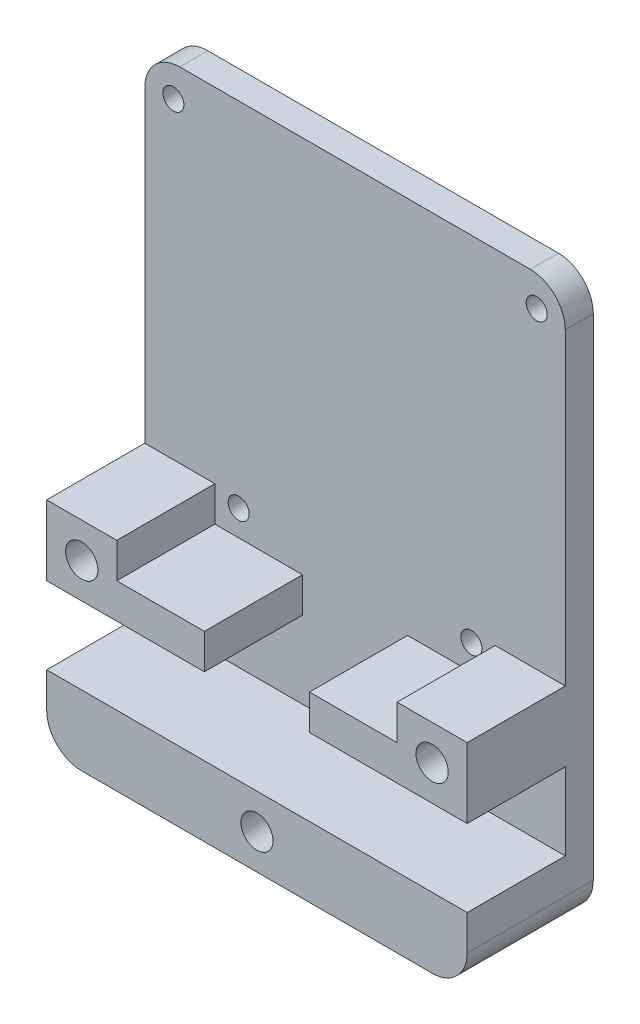
from build123d import *

# Parameters (mm, degrees)
BOSS_EXTRU_1_DEPTH      = 4
BOSS_EXTRU_2_DEPTH      = 14
ESQUISSE3_R             = 1.5
ENL_V_MAT_EXTRU_1_DEPTH = 4
ESQUISSE4_R             = 2.3
ENL_V_MAT_EXTRU_2_DEPTH = 5.7
ESQUISSE5_W             = 0.949786325
ESQUISSE5_H             = 5.291666667
ESQUISSE5_W_2           = 1.831730769
ESQUISSE5_H_2           = 0.881944444
ENL_V_MAT_EXTRU_3_DEPTH = 2


with BuildPart() as part:
    # Esquisse1 → Boss.-Extru.1 (new body)
    with BuildSketch(Plane.XY):
        with BuildLine():
            Line((5, 0), (55, 0))
            ThreePointArc((55, 0), (58.535533906, -1.464466094), (60, -5))
            Line((60, -5), (60, -75))
            ThreePointArc((60, -75), (58.535533906, -78.535533906), (55, -80))
            Line((55, -80), (5, -80))
            ThreePointArc((5, -80), (1.464466094, -78.535533906), (0, -75))
            Line((0, -75), (0, -5))
            ThreePointArc((0, -5), (1.464466094, -1.464466094), (5, 0))
        make_face()
    extrude(amount=BOSS_EXTRU_1_DEPTH)

    # Esquisse2 → Boss.-Extru.2 (add)
    with BuildSketch(Plane.XY.offset(4)):
        with BuildLine():
            ThreePointArc((0, -75), (1.464466094, -78.535533906), (5, -80))
            Line((5, -80), (55, -80))
            ThreePointArc((55, -80), (58.535533906, -78.535533906), (60, -75))
            Line((60, -75), (60, -70))
            Line((60, -70), (0, -70))
            Line((0, -70), (0, -75))
        make_face()
        Polygon((0, -49), (0, -59), (22.5, -59), (22.5, -54), (10, -54), (10, -49), align=None)
        Polygon((37.5, -54), (37.5, -59), (60, -59), (60, -49), (50, -49), (50, -54), align=None)
    extrude(amount=BOSS_EXTRU_2_DEPTH)

    # Esquisse3 → Enlèv. mat.-Extru.1 (cut)
    with BuildSketch(Plane.XY.offset(4)):
        with Locations((55.923551811, -4.402564044)):
            Circle(ESQUISSE3_R)
        with Locations((46.602959843, -50.33119663)):
            Circle(ESQUISSE3_R)
        with Locations((4.076448189, -4.402564044)):
            Circle(ESQUISSE3_R)
        with Locations((13.397040157, -50.33119663)):
            Circle(ESQUISSE3_R)
    extrude(amount=-ENL_V_MAT_EXTRU_1_DEPTH, mode=Mode.SUBTRACT)

    # Esquisse4 → Enlèv. mat.-Extru.2 (cut)
    with BuildSketch(Plane.XY.offset(18)):
        with Locations((55, -54)):
            Circle(ESQUISSE4_R)
        with Locations((5, -54)):
            Circle(ESQUISSE4_R)
        with Locations((30, -75)):
            Circle(ESQUISSE4_R)
    extrude(amount=-ENL_V_MAT_EXTRU_2_DEPTH, mode=Mode.SUBTRACT)

    # Esquisse5 → Enlèv. mat.-Extru.3 (cut)
    with BuildSketch(Plane.XZ.offset(80)):
        with BuildLine():
            Line((9.070779915, 10.868526614), (8.36056023, 10.218728604))
            add(Edge.make_bspline(
                [(8.36056023, 10.218728604), (8.330137464, 10.261643078), (8.271729996, 10.344032884), (8.177057582, 10.454354776), (8.082812663, 10.548467559), (7.988122117, 10.625978075), (7.892146642, 10.68641539), (7.795052838, 10.729205676), (7.697391157, 10.756407867), (7.631777583, 10.759795194), (7.599459135, 10.761463647)],
                knots=[0, 0, 0, 0, 0.000157741, 0.000302842, 0.000435515, 0.000556864, 0.000669227, 0.000774597, 0.000874358, 0.000971193, 0.000971193, 0.000971193, 0.000971193], degree=3))
            add(Edge.make_bspline(
                [(7.599459135, 10.761463647), (7.569313413, 10.760406438), (7.511109944, 10.758365247), (7.428136582, 10.738075955), (7.354471649, 10.703059618), (7.29018704, 10.65727281), (7.239264145, 10.602110323), (7.198606162, 10.544259056), (7.175712301, 10.480404342), (7.172699019, 10.436546348), (7.171207265, 10.414834039)],
                knots=[0, 0, 0, 0, 9.0327e-05, 0.000174397, 0.000254062, 0.00033379, 0.000409528, 0.000478324, 0.000544709, 0.000609795, 0.000609795, 0.000609795, 0.000609795], degree=3))
            add(Edge.make_bspline(
                [(7.171207265, 10.414834039), (7.172142071, 10.39280863), (7.174024641, 10.348452515), (7.192207706, 10.283443106), (7.219614776, 10.219921345), (7.245803351, 10.181252626), (7.259189704, 10.161487018)],
                knots=[0, 0, 0, 0, 6.5935e-05, 0.000132784, 0.000201129, 0.000272593, 0.000272593, 0.000272593, 0.000272593], degree=3))
            add(Edge.make_bspline(
                [(7.259189704, 10.161487018), (7.271359346, 10.146123417), (7.299372257, 10.110758437), (7.35278714, 10.054745821), (7.419865016, 9.986125465), (7.503187181, 9.90725702), (7.599294704, 9.815304068), (7.712642293, 9.713881316), (7.839967309, 9.599847819), (7.930466981, 9.520439021), (7.977889623, 9.478828097)],
                knots=[0, 0, 0, 0, 5.8772e-05, 0.000135285, 0.000231981, 0.000346684, 0.000479408, 0.000631004, 0.000802928, 0.000992196, 0.000992196, 0.000992196, 0.000992196], degree=3))
            add(Edge.make_bspline(
                [(7.977889623, 9.478828097), (8.022402595, 9.440304365), (8.106878967, 9.367194326), (8.227072069, 9.263426364), (8.332701788, 9.170068859), (8.425306907, 9.088522907), (8.503483624, 9.017932905), (8.567560593, 8.957961432), (8.618320407, 8.909776024), (8.647174388, 8.880672008), (8.659488515, 8.868251173)],
                knots=[0, 0, 0, 0, 0.000176605, 0.000335161, 0.000476363, 0.000599519, 0.000705336, 0.000792336, 0.00086281, 0.000915279, 0.000915279, 0.000915279, 0.000915279], degree=3))
            add(Edge.make_bspline(
                [(8.659488515, 8.868251173), (8.706205744, 8.817693126), (8.796012664, 8.720502805), (8.912730002, 8.569888372), (9.008792146, 8.422857975), (9.083107642, 8.276644998), (9.139233694, 8.129139878), (9.178803304, 7.976725061), (9.202501807, 7.817807908), (9.205132894, 7.709366351), (9.206463675, 7.654517533)],
                knots=[0, 0, 0, 0, 0.000206434, 0.000396838, 0.000570906, 0.000732563, 0.000887896, 0.001043446, 0.001204152, 0.001368624, 0.001368624, 0.001368624, 0.001368624], degree=3))
            add(Edge.make_bspline(
                [(9.206463675, 7.654517533), (9.205516459, 7.601074086), (9.203657986, 7.496216055), (9.18089525, 7.342771945), (9.148436925, 7.195919272), (9.09825066, 7.057256001), (9.037083938, 6.924506017), (8.960402618, 6.799737142), (8.870350922, 6.681686664), (8.767137851, 6.57246488), (8.652971939, 6.473353681), (8.530518148, 6.385122551), (8.398579064, 6.312276515), (8.258281953, 6.252293), (8.109701912, 6.206092894), (7.953015947, 6.171946711), (7.787984394, 6.15145271), (7.67513344, 6.149310305), (7.617479634, 6.148215784)],
                knots=[0, 0, 0, 0, 0.000160191, 0.0003143, 0.000464466, 0.000610642, 0.000755754, 0.000902284, 0.001048997, 0.001200474, 0.001352247, 0.001501966, 0.00165239, 0.00180341, 0.00195897, 0.002118444, 0.002283979, 0.00245688, 0.00245688, 0.00245688, 0.00245688], degree=3))
            add(Edge.make_bspline(
                [(7.617479634, 6.148215784), (7.572221887, 6.149018686), (7.482585593, 6.150608894), (7.350475247, 6.163591615), (7.222907773, 6.184544346), (7.100026866, 6.214575868), (6.981278925, 6.25262988), (6.866659072, 6.299111397), (6.756958568, 6.354740867), (6.651347365, 6.418374325), (6.550338865, 6.492261153), (6.452655855, 6.574890757), (6.359268615, 6.667534018), (6.269728626, 6.769971839), (6.184608789, 6.882494298), (6.101122827, 7.003534313), (6.022981106, 7.135338221), (5.974709489, 7.227799729), (5.950053419, 7.275027015)],
                knots=[0, 0, 0, 0, 0.00013575, 0.000268863, 0.000397821, 0.000523286, 0.000647991, 0.000771611, 0.000893919, 0.001016631, 0.001141093, 0.001268949, 0.001400123, 0.001535342, 0.001676756, 0.001823178, 0.001976248, 0.002136063, 0.002136063, 0.002136063, 0.002136063], degree=3))
            Line((5.950053419, 7.275027015), (6.785356571, 7.776420912))
            add(Edge.make_bspline(
                [(6.785356571, 7.776420912), (6.816197629, 7.722811772), (6.875322575, 7.620038469), (6.975515323, 7.481949511), (7.078157679, 7.363699176), (7.185622641, 7.267377547), (7.296603476, 7.191696679), (7.411636247, 7.137609881), (7.530801774, 7.104130214), (7.611971918, 7.100041574), (7.652460604, 7.098002108)],
                knots=[0, 0, 0, 0, 0.000185429, 0.000355484, 0.000510947, 0.000654349, 0.000787238, 0.000912434, 0.001034319, 0.001155626, 0.001155626, 0.001155626, 0.001155626], degree=3))
            add(Edge.make_bspline(
                [(7.652460604, 7.098002108), (7.693643394, 7.099667646), (7.773544005, 7.102899032), (7.887591903, 7.132746371), (7.992155334, 7.179608883), (8.082539192, 7.246475226), (8.159070544, 7.323649148), (8.215555075, 7.409508665), (8.251039038, 7.50240659), (8.254790553, 7.566939599), (8.25667735, 7.599396005)],
                knots=[0, 0, 0, 0, 0.000123333, 0.000239284, 0.000351226, 0.000465089, 0.000574534, 0.000675677, 0.000771585, 0.000868628, 0.000868628, 0.000868628, 0.000868628], degree=3))
            add(Edge.make_bspline(
                [(8.25667735, 7.599396005), (8.25493497, 7.629591409), (8.251395492, 7.690930482), (8.225324787, 7.782131819), (8.184568324, 7.87329168), (8.136350553, 7.948063465), (8.087282934, 8.010667853), (8.040363223, 8.064911723), (7.983227426, 8.124841703), (7.916020416, 8.190533181), (7.839630171, 8.262564455), (7.753992343, 8.340928472), (7.658126289, 8.424934937), (7.590367972, 8.482159312), (7.554937901, 8.512081302)],
                knots=[0, 0, 0, 0, 9.0501e-05, 0.000183843, 0.00028254, 0.000389288, 0.000449719, 0.000521119, 0.00060435, 0.000698048, 0.000803028, 0.000919327, 0.00104627, 0.001185392, 0.001185392, 0.001185392, 0.001185392], degree=3))
            add(Edge.make_bspline(
                [(7.554937901, 8.512081302), (7.487583925, 8.569069224), (7.358311259, 8.678446296), (7.17563258, 8.839992788), (7.011022734, 8.990972787), (6.865903468, 9.133252736), (6.738425737, 9.264205054), (6.629452877, 9.384893386), (6.540182004, 9.496248677), (6.446243659, 9.628141568), (6.356983449, 9.788862118), (6.279837298, 9.982227571), (6.229788132, 10.175568489), (6.224180819, 10.305366933), (6.22142094, 10.369252776)],
                knots=[0, 0, 0, 0, 0.000264676, 0.000507994, 0.000731542, 0.000934684, 0.0011176, 0.001279753, 0.00142229, 0.001545519, 0.001765234, 0.001971722, 0.002169175, 0.002360557, 0.002360557, 0.002360557, 0.002360557], degree=3))
            add(Edge.make_bspline(
                [(6.22142094, 10.369252776), (6.22256877, 10.414557187), (6.224830118, 10.503811744), (6.24500169, 10.635047565), (6.275148873, 10.761679105), (6.318931238, 10.883244355), (6.375755462, 10.999591049), (6.444766274, 11.111288754), (6.527035282, 11.21730943), (6.6197469, 11.31758279), (6.721891366, 11.409221231), (6.831045708, 11.490101338), (6.946592105, 11.558413851), (7.0678237, 11.615084042), (7.195491716, 11.658461473), (7.328655628, 11.689209558), (7.467506436, 11.707497538), (7.561949758, 11.709983577), (7.610059428, 11.711249972)],
                knots=[0, 0, 0, 0, 0.000135833, 0.000267605, 0.00039744, 0.000525861, 0.000654339, 0.000785243, 0.00091903, 0.001056299, 0.00119442, 0.001330108, 0.001463183, 0.001596448, 0.001730871, 0.001866894, 0.002005871, 0.002150175, 0.002150175, 0.002150175, 0.002150175], degree=3))
            add(Edge.make_bspline(
                [(7.610059428, 11.711249972), (7.67240718, 11.708969158), (7.79661053, 11.704425535), (7.980248767, 11.668895886), (8.159618919, 11.613021771), (8.304158748, 11.545615799), (8.419166393, 11.480319601), (8.507309009, 11.420203088), (8.596998866, 11.35133639), (8.688959255, 11.273502492), (8.781481412, 11.1852349), (8.877196183, 11.088634894), (8.974799337, 10.982867624), (9.038225912, 10.907307976), (9.070779915, 10.868526614)],
                knots=[0, 0, 0, 0, 0.000186929, 0.000372383, 0.00055912, 0.000749317, 0.000849506, 0.000955641, 0.001069069, 0.001188646, 0.001316874, 0.001452546, 0.001596585, 0.001748469, 0.001748469, 0.001748469, 0.001748469], degree=3))
        make_face()
        with BuildLine():
            Line((14.701655983, 7.037580434), (15.599500868, 5.876848262))
            Line((15.599500868, 5.876848262), (14.41650808, 5.876848262))
            Line((14.41650808, 5.876848262), (13.951155182, 6.477884921))
            add(Edge.make_bspline(
                [(13.951155182, 6.477884921), (13.902410877, 6.451343189), (13.805152194, 6.398384924), (13.652637751, 6.332346391), (13.497299991, 6.274412569), (13.336888026, 6.229015651), (13.172941949, 6.193282765), (13.004612285, 6.166000121), (12.832019483, 6.151614589), (12.715537544, 6.149354375), (12.656859308, 6.148215784)],
                knots=[0, 0, 0, 0, 0.000166428, 0.000332071, 0.000498076, 0.000663485, 0.000831696, 0.001001264, 0.001174685, 0.00135073, 0.00135073, 0.00135073, 0.00135073], degree=3))
            add(Edge.make_bspline(
                [(12.656859308, 6.148215784), (12.559543707, 6.150453356), (12.367981748, 6.154857929), (12.08769118, 6.195726237), (11.819203918, 6.258530067), (11.563893835, 6.349379425), (11.32040608, 6.465140696), (11.090973572, 6.608556123), (10.872937793, 6.775695194), (10.671630507, 6.968185769), (10.487437633, 7.176785904), (10.326497058, 7.398407586), (10.189687011, 7.629593292), (10.078114546, 7.870705609), (9.991355616, 8.12216023), (9.930599023, 8.383270347), (9.892080315, 8.654396813), (9.887305821, 8.838439992), (9.884882479, 8.931852936)],
                knots=[0, 0, 0, 0, 0.000291785, 0.000574368, 0.000847932, 0.001117823, 0.001385709, 0.001655157, 0.001928029, 0.002208463, 0.002489372, 0.002761833, 0.003028895, 0.003294017, 0.003557506, 0.003825423, 0.004097215, 0.004377352, 0.004377352, 0.004377352, 0.004377352], degree=3))
            add(Edge.make_bspline(
                [(9.884882479, 8.931852936), (9.885690327, 8.994445179), (9.887295795, 9.118837104), (9.906605037, 9.303183897), (9.934464255, 9.483915611), (9.975368671, 9.660060785), (10.025806622, 9.832911694), (10.089981998, 10.001094), (10.164355254, 10.166204728), (10.249677841, 10.326872207), (10.346592799, 10.480720886), (10.449579694, 10.628973225), (10.564136301, 10.766869144), (10.68620796, 10.897514103), (10.816195633, 11.02082253), (10.95614643, 11.134252773), (11.103400898, 11.240619766), (11.259020035, 11.337693549), (11.420302243, 11.425438826), (11.585763112, 11.501695423), (11.754143272, 11.566932183), (11.925505547, 11.620075134), (12.100371184, 11.659900418), (12.277201506, 11.690223044), (12.457599957, 11.707090342), (12.578738206, 11.709854431), (12.639898838, 11.711249972)],
                knots=[0, 0, 0, 0, 0.0001877, 0.000373023, 0.000555487, 0.000736004, 0.000915108, 0.001095253, 0.001275536, 0.001458111, 0.001640476, 0.001820759, 0.001999238, 0.002177732, 0.002356953, 0.002536251, 0.002717764, 0.00290159, 0.003086102, 0.00326823, 0.003447763, 0.003627481, 0.003805931, 0.003985427, 0.004165373, 0.004348869, 0.004348869, 0.004348869, 0.004348869], degree=3))
            add(Edge.make_bspline(
                [(12.639898838, 11.711249972), (12.73226122, 11.708901366), (12.914261451, 11.704273434), (13.181982609, 11.664700456), (13.440157504, 11.601661656), (13.687721556, 11.510582939), (13.926187877, 11.395744842), (14.153179836, 11.253651029), (14.371099424, 11.08723169), (14.575238822, 10.896406908), (14.763893675, 10.689316068), (14.928356192, 10.467130677), (15.067583608, 10.234092979), (15.183693135, 9.990110066), (15.271168845, 9.733756041), (15.333616005, 9.466732931), (15.37314324, 9.188852876), (15.377739125, 8.999475197), (15.380074786, 8.903232143)],
                knots=[0, 0, 0, 0, 0.00027696, 0.00054575, 0.000810044, 0.001072953, 0.001335603, 0.00160269, 0.001874918, 0.002156945, 0.002439886, 0.002714226, 0.002984736, 0.003253124, 0.003523317, 0.003795604, 0.004074891, 0.0043635, 0.0043635, 0.0043635, 0.0043635], degree=3))
            add(Edge.make_bspline(
                [(15.380074786, 8.903232143), (15.378133015, 8.814440505), (15.374313934, 8.639804853), (15.341228163, 8.382355671), (15.289004758, 8.134209144), (15.213999211, 7.895188923), (15.118946591, 7.665555532), (15.000510741, 7.445992604), (14.863939262, 7.233893477), (14.756020092, 7.103344349), (14.701655983, 7.037580434)],
                knots=[0, 0, 0, 0, 0.000266278, 0.000523717, 0.000777363, 0.001026134, 0.001274181, 0.001521729, 0.001773697, 0.002029472, 0.002029472, 0.002029472, 0.002029472], degree=3))
        make_face()
        with BuildLine():
            add(Edge.make_bspline(
                [(14.078358707, 7.845322821), (14.106630862, 7.885856341), (14.162523804, 7.96598952), (14.23324642, 8.093091639), (14.293997947, 8.222670291), (14.344237081, 8.355405425), (14.382453933, 8.492057723), (14.409617608, 8.631735076), (14.427605883, 8.774501451), (14.429389593, 8.870670113), (14.430288462, 8.919132584)],
                knots=[0, 0, 0, 0, 0.000148177, 0.00029294, 0.000435682, 0.000577243, 0.000718191, 0.000860803, 0.001003856, 0.001149177, 0.001149177, 0.001149177, 0.001149177], degree=3))
            add(Edge.make_bspline(
                [(14.430288462, 8.919132584), (14.428615522, 8.98210426), (14.425322597, 9.106054401), (14.400590092, 9.288262934), (14.359156726, 9.462884521), (14.301384114, 9.630346567), (14.228628656, 9.791078946), (14.13723243, 9.943743282), (14.029853869, 10.089132488), (13.907529525, 10.225846406), (13.774350427, 10.350969905), (13.632711222, 10.461166941), (13.483583506, 10.554133618), (13.32688004, 10.62919814), (13.164300681, 10.689657285), (12.994100706, 10.730237774), (12.817763595, 10.756845095), (12.697592619, 10.759910721), (12.63671875, 10.761463647)],
                knots=[0, 0, 0, 0, 0.000188876, 0.000371773, 0.000550466, 0.000726459, 0.000902443, 0.001078785, 0.001259208, 0.001443896, 0.001628384, 0.001806702, 0.001981427, 0.002154475, 0.002327182, 0.002500723, 0.002678517, 0.002861039, 0.002861039, 0.002861039, 0.002861039], degree=3))
            add(Edge.make_bspline(
                [(12.63671875, 10.761463647), (12.574092031, 10.759825131), (12.450829249, 10.75660018), (12.269868851, 10.731390701), (12.096289609, 10.691848693), (11.931003929, 10.633791015), (11.773511356, 10.560637075), (11.623819115, 10.470875768), (11.482677403, 10.364004478), (11.349750652, 10.243153559), (11.229646684, 10.109052672), (11.123587779, 9.965251559), (11.034819227, 9.812096974), (10.960478815, 9.65098361), (10.904516016, 9.480107285), (10.864655642, 9.300804477), (10.839465309, 9.112766792), (10.836290042, 8.984581726), (10.834668803, 8.919132584)],
                knots=[0, 0, 0, 0, 0.000187817, 0.000369664, 0.000547082, 0.000721072, 0.000894168, 0.001067236, 0.001243625, 0.001424455, 0.001605361, 0.00178282, 0.001959537, 0.002135521, 0.002314188, 0.002497806, 0.002685957, 0.002882246, 0.002882246, 0.002882246, 0.002882246], degree=3))
            add(Edge.make_bspline(
                [(10.834668803, 8.919132584), (10.836817846, 8.846599879), (10.841029613, 8.704447796), (10.870677316, 8.49708582), (10.921366223, 8.301231684), (10.994681259, 8.117942767), (11.085278925, 7.944638418), (11.199416501, 7.785009706), (11.332137521, 7.635900404), (11.434588535, 7.549105548), (11.486586872, 7.50505339)],
                knots=[0, 0, 0, 0, 0.000217564, 0.00042639, 0.000626938, 0.000822994, 0.001017417, 0.001212116, 0.001410276, 0.001614507, 0.001614507, 0.001614507, 0.001614507], degree=3))
            add(Edge.make_bspline(
                [(11.486586872, 7.50505339), (11.529131407, 7.472443601), (11.613500811, 7.407775636), (11.748653176, 7.325919033), (11.887176403, 7.254809838), (12.030380302, 7.197958809), (12.17777017, 7.152745407), (12.329314666, 7.121425908), (12.485309808, 7.101489705), (12.590722994, 7.099175025), (12.644138956, 7.098002108)],
                knots=[0, 0, 0, 0, 0.000160705, 0.000318693, 0.000473239, 0.000627367, 0.000780276, 0.00093516, 0.001091096, 0.001251286, 0.001251286, 0.001251286, 0.001251286], degree=3))
            add(Edge.make_bspline(
                [(12.644138956, 7.098002108), (12.705401527, 7.10008179), (12.826935315, 7.104207499), (13.005938566, 7.135978438), (13.179768275, 7.187287451), (13.288855403, 7.238600932), (13.343758347, 7.264426721)],
                knots=[0, 0, 0, 0, 0.000183691, 0.00036441, 0.000543818, 0.000725606, 0.000725606, 0.000725606, 0.000725606], degree=3))
            Line((13.343758347, 7.264426721), (12.424712874, 8.454839715))
            Line((12.424712874, 8.454839715), (13.607705662, 8.454839715))
            Line((13.607705662, 8.454839715), (14.078358707, 7.845322821))
        make_face(mode=Mode.SUBTRACT)
        with BuildLine():
            Line((16.329861111, 11.575566211), (17.279647436, 11.575566211))
            Line((17.279647436, 11.575566211), (17.279647436, 8.132590784))
            add(Edge.make_bspline(
                [(17.279647436, 8.132590784), (17.279699081, 8.096895508), (17.279798832, 8.027950451), (17.284792429, 7.929036868), (17.289361914, 7.838114574), (17.297606563, 7.755283111), (17.309786735, 7.680507046), (17.321581116, 7.613306045), (17.337543645, 7.554883264), (17.361532774, 7.488382844), (17.398492146, 7.41366599), (17.458881709, 7.335794371), (17.528566099, 7.264725216), (17.612086854, 7.205569944), (17.705956796, 7.157718661), (17.809660152, 7.122266156), (17.923050736, 7.10255927), (18.001454106, 7.099550653), (18.04180856, 7.098002108)],
                knots=[0, 0, 0, 0, 0.000107068, 0.000206801, 0.000297059, 0.000380175, 0.000456335, 0.000524318, 0.000584749, 0.000637729, 0.000736335, 0.000833222, 0.000932163, 0.001033948, 0.001138719, 0.001247329, 0.001361483, 0.001482554, 0.001482554, 0.001482554, 0.001482554], degree=3))
            add(Edge.make_bspline(
                [(18.04180856, 7.098002108), (18.084680189, 7.099253133), (18.168272605, 7.101692421), (18.288506989, 7.125636665), (18.399904828, 7.163764102), (18.500107449, 7.218181672), (18.589015134, 7.283410667), (18.664273627, 7.357792161), (18.723667354, 7.44147451), (18.762377975, 7.518677849), (18.784112082, 7.589736799), (18.800402878, 7.653225275), (18.812345834, 7.728135392), (18.823180876, 7.813297268), (18.829691902, 7.909593014), (18.836752047, 8.016248209), (18.839339656, 8.133992615), (18.839780695, 8.215980256), (18.840010684, 8.25873428)],
                knots=[0, 0, 0, 0, 0.000128478, 0.00025051, 0.00036617, 0.000480467, 0.000591137, 0.000696075, 0.000796381, 0.000897834, 0.000953483, 0.001019042, 0.001094326, 0.001180841, 0.001276531, 0.001383783, 0.001501489, 0.001629757, 0.001629757, 0.001629757, 0.001629757], degree=3))
            Line((18.840010684, 8.25873428), (18.840010684, 11.575566211))
            Line((18.840010684, 11.575566211), (19.789797009, 11.575566211))
            Line((19.789797009, 11.575566211), (19.789797009, 8.418798716))
            add(Edge.make_bspline(
                [(19.789797009, 8.418798716), (19.789665113, 8.354842758), (19.789411492, 8.231861687), (19.785516632, 8.055129233), (19.777225179, 7.893712486), (19.770261315, 7.74756428), (19.756783854, 7.616881501), (19.742743501, 7.501106095), (19.724847863, 7.400648345), (19.698220229, 7.286289404), (19.652268817, 7.154609273), (19.578189117, 7.00298531), (19.484149732, 6.854536265), (19.372999878, 6.710895182), (19.247501526, 6.577457244), (19.110437243, 6.460316007), (18.96398464, 6.361227153), (18.806613391, 6.282613522), (18.638457428, 6.221300816), (18.457852973, 6.180101766), (18.264923184, 6.152267171), (18.131662932, 6.149593316), (18.063009148, 6.148215784)],
                knots=[0, 0, 0, 0, 0.000191868, 0.000368944, 0.000530239, 0.000676769, 0.000807771, 0.000924264, 0.001026566, 0.001113728, 0.001276313, 0.001443667, 0.001618954, 0.001802572, 0.001987786, 0.002167494, 0.002342425, 0.002516879, 0.002693933, 0.002878027, 0.003071714, 0.003277535, 0.003277535, 0.003277535, 0.003277535], degree=3))
            add(Edge.make_bspline(
                [(18.063009148, 6.148215784), (18.017394208, 6.148984107), (17.927396868, 6.150499993), (17.79503999, 6.163866151), (17.667091068, 6.183562842), (17.543790516, 6.212298286), (17.424710382, 6.249419112), (17.309882303, 6.295112263), (17.199733006, 6.34912287), (17.094878872, 6.410954151), (16.995448934, 6.477814037), (16.904575102, 6.551931036), (16.819130196, 6.627823915), (16.741582683, 6.708686568), (16.671350112, 6.793670076), (16.608577128, 6.88296704), (16.553356989, 6.976569527), (16.504300664, 7.076164717), (16.462313238, 7.186814674), (16.42691626, 7.312455262), (16.395992627, 7.455055773), (16.373012008, 7.614937476), (16.352177644, 7.791573421), (16.33899064, 7.985423771), (16.332091925, 8.196494088), (16.330623505, 8.342824762), (16.329861111, 8.418798716)],
                knots=[0, 0, 0, 0, 0.00013681, 0.000269922, 0.00039871, 0.000524961, 0.000649346, 0.00077257, 0.000895355, 0.001016981, 0.001137527, 0.001254404, 0.001368494, 0.0014802, 0.001590137, 0.001698949, 0.001807301, 0.001915864, 0.002031621, 0.002161794, 0.002307126, 0.002469036, 0.00264615, 0.002840624, 0.003051701, 0.003279629, 0.003279629, 0.003279629, 0.003279629], degree=3))
            Line((16.329861111, 8.418798716), (16.329861111, 11.575566211))
        make_face()
        with Locations((21.350160257, 8.929732878)):
            Rectangle(ESQUISSE5_W, ESQUISSE5_H)
        with BuildLine():
            Line((23.046207265, 11.575566211), (24.152877938, 11.575566211))
            add(Edge.make_bspline(
                [(24.152877938, 11.575566211), (24.226028533, 11.575306568), (24.366717732, 11.574807202), (24.569583872, 11.566928531), (24.755944321, 11.555964713), (24.926075001, 11.539233636), (25.079903128, 11.51705025), (25.217582875, 11.49089971), (25.339110215, 11.461095562), (25.445510066, 11.423957242), (25.541530669, 11.38206578), (25.631035221, 11.333931723), (25.715998325, 11.280091057), (25.795852094, 11.21912709), (25.871290477, 11.152136548), (25.942455791, 11.079051999), (26.008342407, 10.999253715), (26.06854235, 10.913245921), (26.123409752, 10.822767694), (26.171901029, 10.727694806), (26.211334215, 10.627961142), (26.246177662, 10.525008067), (26.271274269, 10.417363849), (26.288728591, 10.30607642), (26.301507963, 10.190754038), (26.302242716, 10.112409132), (26.302617521, 10.07244455)],
                knots=[0, 0, 0, 0, 0.000219436, 0.000422038, 0.000608967, 0.000779418, 0.000934726, 0.001075054, 0.001199746, 0.001309704, 0.001412707, 0.001513721, 0.00161429, 0.001714147, 0.001814766, 0.001916717, 0.002019867, 0.002124858, 0.002231389, 0.002337106, 0.002444582, 0.002552856, 0.0026629, 0.002775653, 0.002890728, 0.003010554, 0.003010554, 0.003010554, 0.003010554], degree=3))
            add(Edge.make_bspline(
                [(26.302617521, 10.07244455), (26.301643912, 10.030730706), (26.299734841, 9.948937462), (26.289451548, 9.828789858), (26.270656917, 9.713841034), (26.242189715, 9.604427546), (26.209470364, 9.499187617), (26.16596202, 9.400062988), (26.116858553, 9.305612035), (26.058539801, 9.217170804), (25.994537819, 9.132774837), (25.92010486, 9.055657657), (25.840063037, 8.981674508), (25.749912908, 8.915459443), (25.653628373, 8.852535239), (25.54929636, 8.795509153), (25.437597776, 8.74294768), (25.35906814, 8.713635772), (25.318910256, 8.698646473)],
                knots=[0, 0, 0, 0, 0.000125155, 0.000245407, 0.000361469, 0.000474077, 0.000584366, 0.00069168, 0.00079837, 0.000903334, 0.001009136, 0.001115615, 0.001224427, 0.00133573, 0.001450693, 0.001569302, 0.001692129, 0.001820672, 0.001820672, 0.001820672, 0.001820672], degree=3))
            Line((25.318910256, 8.698646473), (26.540064103, 6.283899544))
            Line((26.540064103, 6.283899544), (25.48427484, 6.283899544))
            Line((25.48427484, 6.283899544), (24.318242521, 8.590523476))
            Line((24.318242521, 8.590523476), (23.99599359, 8.590523476))
            Line((23.99599359, 8.590523476), (23.99599359, 6.283899544))
            Line((23.99599359, 6.283899544), (23.046207265, 6.283899544))
            Line((23.046207265, 6.283899544), (23.046207265, 11.575566211))
        make_face()
        with BuildLine():
            Line((23.99599359, 9.540309801), (24.365943843, 9.540309801))
            add(Edge.make_bspline(
                [(24.365943843, 9.540309801), (24.411173337, 9.540819206), (24.497778099, 9.541794607), (24.622327121, 9.546318921), (24.735447337, 9.557220283), (24.837624523, 9.570993746), (24.929372824, 9.586897199), (25.009873879, 9.609687812), (25.080368086, 9.63410853), (25.140020085, 9.664457149), (25.190985383, 9.69897011), (25.234990656, 9.738177693), (25.271389326, 9.783555477), (25.301347288, 9.833870291), (25.324651325, 9.889567156), (25.341661487, 9.950034647), (25.351167653, 10.015961567), (25.352261369, 10.061460119), (25.352831197, 10.085164902)],
                knots=[0, 0, 0, 0, 0.0001357, 0.000259837, 0.000373754, 0.000476446, 0.000569173, 0.000652754, 0.000727198, 0.00079262, 0.000852893, 0.000911435, 0.000968715, 0.001026708, 0.00108656, 0.001149317, 0.001214678, 0.001285772, 0.001285772, 0.001285772, 0.001285772], degree=3))
            add(Edge.make_bspline(
                [(25.352831197, 10.085164902), (25.351753886, 10.113209392), (25.349637709, 10.168297594), (25.328638656, 10.24760529), (25.295212699, 10.321009988), (25.249394868, 10.388180028), (25.191693266, 10.447065923), (25.125476125, 10.498974307), (25.04931432, 10.540019574), (24.97879422, 10.567092595), (24.914637413, 10.583290663), (24.856737918, 10.595361319), (24.789689954, 10.60391614), (24.713442904, 10.612990051), (24.628191124, 10.618874022), (24.533469941, 10.623168149), (24.429551394, 10.624925087), (24.357110296, 10.625486749), (24.319302551, 10.625779886)],
                knots=[0, 0, 0, 0, 8.3983e-05, 0.00016497, 0.000244189, 0.000325044, 0.000407508, 0.000490624, 0.000576493, 0.00066607, 0.000716464, 0.000774881, 0.00084339, 0.000919128, 0.001005226, 0.001099664, 0.001203568, 0.001316997, 0.001316997, 0.001316997, 0.001316997], degree=3))
            Line((24.319302551, 10.625779886), (23.99599359, 10.625779886))
            Line((23.99599359, 10.625779886), (23.99599359, 9.540309801))
        make_face(mode=Mode.SUBTRACT)
        Polygon((27.320245726, 11.575566211), (28.270032051, 11.575566211), (28.270032051, 7.233685869), (29.762553419, 7.233685869), (29.762553419, 6.283899544), (27.320245726, 6.283899544), align=None)
        Polygon((30.576655983, 11.575566211), (33.426014957, 11.575566211), (33.426014957, 10.625779886), (31.526442308, 10.625779886), (31.526442308, 9.608151681), (33.426014957, 9.608151681), (33.426014957, 8.658365356), (31.526442308, 8.658365356), (31.526442308, 7.233685869), (33.426014957, 7.233685869), (33.426014957, 6.283899544), (30.576655983, 6.283899544), align=None)
        with BuildLine():
            Line((34.375801282, 6.283899544), (34.375801282, 11.575566211))
            Line((34.375801282, 11.575566211), (35.223824786, 11.575566211))
            add(Edge.make_bspline(
                [(35.223824786, 11.575566211), (35.283191734, 11.575572986), (35.398065652, 11.575586096), (35.563798737, 11.569766094), (35.717502177, 11.56223727), (35.858686828, 11.553814266), (35.987592995, 11.539299748), (36.104024656, 11.524003031), (36.208214443, 11.505556134), (36.272629327, 11.489008695), (36.302934696, 11.481223596)],
                knots=[0, 0, 0, 0, 0.000178088, 0.000344597, 0.000497422, 0.000639786, 0.000768787, 0.00088647, 0.00099209, 0.001085931, 0.001085931, 0.001085931, 0.001085931], degree=3))
            add(Edge.make_bspline(
                [(36.302934696, 11.481223596), (36.342728722, 11.470242575), (36.420817377, 11.448694288), (36.53266525, 11.40517659), (36.63876856, 11.356803583), (36.738997757, 11.301619029), (36.832737395, 11.238956696), (36.919631229, 11.168319278), (37.001553346, 11.092542156), (37.075594878, 11.009513444), (37.142516224, 10.92177823), (37.200658875, 10.829359502), (37.251177387, 10.733670403), (37.291605428, 10.633506751), (37.322067198, 10.529329824), (37.34434681, 10.421584475), (37.358787015, 10.309929772), (37.360151425, 10.233967428), (37.360844017, 10.195407958)],
                knots=[0, 0, 0, 0, 0.000123769, 0.000242875, 0.000359556, 0.000473429, 0.000585737, 0.000697317, 0.000809064, 0.00092016, 0.001030616, 0.001139722, 0.001247351, 0.001354827, 0.001463163, 0.001572516, 0.001684669, 0.00180029, 0.00180029, 0.00180029, 0.00180029], degree=3))
            add(Edge.make_bspline(
                [(37.360844017, 10.195407958), (37.359033094, 10.14586916), (37.355468515, 10.048358123), (37.332697742, 9.905132052), (37.289998993, 9.769762829), (37.234128719, 9.639755649), (37.158162614, 9.515595441), (37.061700352, 9.397341239), (36.946304307, 9.28135182), (36.85778917, 9.211823986), (36.811748798, 9.175659694)],
                knots=[0, 0, 0, 0, 0.000148646, 0.000292592, 0.00043342, 0.000573448, 0.000716159, 0.000868464, 0.001030368, 0.001205863, 0.001205863, 0.001205863, 0.001205863], degree=3))
            add(Edge.make_bspline(
                [(36.811748798, 9.175659694), (36.849057707, 9.156613819), (36.922210155, 9.119270129), (37.02606514, 9.05788825), (37.12222352, 8.992600836), (37.211116439, 8.924721498), (37.290879267, 8.851372731), (37.364805545, 8.776780991), (37.429248134, 8.696672484), (37.486874639, 8.613902427), (37.536962661, 8.527272302), (37.580583804, 8.436928407), (37.617429019, 8.342562108), (37.648630501, 8.244653652), (37.671900574, 8.142866281), (37.687073156, 8.037163591), (37.698690234, 7.927906082), (37.699593933, 7.853482595), (37.700053419, 7.815641999)],
                knots=[0, 0, 0, 0, 0.000125648, 0.000246361, 0.000361612, 0.0004742, 0.000581515, 0.000686463, 0.000788941, 0.000889504, 0.000988774, 0.001088811, 0.001190187, 0.00129244, 0.00139684, 0.001502981, 0.001612677, 0.001726145, 0.001726145, 0.001726145, 0.001726145], degree=3))
            add(Edge.make_bspline(
                [(37.700053419, 7.815641999), (37.697071664, 7.743368624), (37.691187183, 7.600737408), (37.648162726, 7.391322026), (37.57357199, 7.19277725), (37.473412012, 7.005892181), (37.349995648, 6.836076837), (37.208102221, 6.687320069), (37.049160273, 6.561400768), (36.902517115, 6.476415008), (36.775682332, 6.419381616), (36.670627451, 6.384119976), (36.557800735, 6.351453646), (36.43513547, 6.328514675), (36.304855411, 6.307518406), (36.165690318, 6.294554875), (36.017900288, 6.285769809), (35.916391707, 6.28453557), (35.864082532, 6.283899544)],
                knots=[0, 0, 0, 0, 0.000216755, 0.000427764, 0.000638059, 0.000851001, 0.001061971, 0.001265899, 0.001465886, 0.00166824, 0.001772641, 0.001882598, 0.002000395, 0.002124713, 0.002256643, 0.002396189, 0.002543777, 0.002700693, 0.002700693, 0.002700693, 0.002700693], degree=3))
            Line((35.864082532, 6.283899544), (34.375801282, 6.283899544))
        make_face()
        with BuildLine():
            Line((35.325587607, 10.625779886), (35.325587607, 9.47246792))
            Line((35.325587607, 9.47246792), (35.577874599, 9.47246792))
            add(Edge.make_bspline(
                [(35.577874599, 9.47246792), (35.612162668, 9.472766925), (35.67835371, 9.473344136), (35.77395965, 9.480778413), (35.862857733, 9.49346175), (35.94471079, 9.511158196), (36.020281311, 9.533630102), (36.08908653, 9.560668645), (36.150823923, 9.593658606), (36.222548494, 9.64279861), (36.298366538, 9.715110324), (36.36510831, 9.819579578), (36.404418768, 9.939718823), (36.408796892, 10.024450321), (36.411057692, 10.068204432)],
                knots=[0, 0, 0, 0, 0.000102845, 0.000198535, 0.000287433, 0.000372056, 0.000449525, 0.000523735, 0.000593447, 0.000659015, 0.000784211, 0.00090478, 0.001027469, 0.001158471, 0.001158471, 0.001158471, 0.001158471], degree=3))
            add(Edge.make_bspline(
                [(36.411057692, 10.068204432), (36.409248639, 10.109187427), (36.405750906, 10.1884264), (36.366170329, 10.299684976), (36.304693868, 10.398282844), (36.232112266, 10.465765022), (36.163762583, 10.511853359), (36.105237391, 10.542200567), (36.041001597, 10.569367077), (35.969811666, 10.590139253), (35.892074132, 10.605725963), (35.808166609, 10.617172534), (35.717944328, 10.624963558), (35.655627606, 10.62550194), (35.623455863, 10.625779886)],
                knots=[0, 0, 0, 0, 0.00012246, 0.000236771, 0.000349698, 0.000468165, 0.000530788, 0.000596697, 0.000665599, 0.000739718, 0.000818717, 0.000903267, 0.000993675, 0.001090161, 0.001090161, 0.001090161, 0.001090161], degree=3))
            Line((35.623455863, 10.625779886), (35.325587607, 10.625779886))
        make_face(mode=Mode.SUBTRACT)
        with BuildLine():
            Line((35.325587607, 8.590523476), (35.325587607, 7.233685869))
            Line((35.325587607, 7.233685869), (35.599075187, 7.233685869))
            add(Edge.make_bspline(
                [(35.599075187, 7.233685869), (35.65314403, 7.233994762), (35.757098127, 7.234588648), (35.906012187, 7.241764202), (36.041412296, 7.254696874), (36.162939695, 7.270842272), (36.270780526, 7.292716762), (36.364570262, 7.320527373), (36.445595106, 7.351123888), (36.51336923, 7.388914218), (36.568736807, 7.43289279), (36.61870024, 7.477839947), (36.65943731, 7.529690739), (36.69166924, 7.586219356), (36.719565919, 7.646021585), (36.736391225, 7.711432683), (36.749201423, 7.78051402), (36.749906402, 7.828296087), (36.750267094, 7.852743027)],
                knots=[0, 0, 0, 0, 0.000162198, 0.000311847, 0.00044707, 0.000570148, 0.0006795, 0.000776769, 0.000863381, 0.000938852, 0.001008395, 0.001075143, 0.001140039, 0.001205125, 0.001270133, 0.001337259, 0.001407141, 0.001480352, 0.001480352, 0.001480352, 0.001480352], degree=3))
            add(Edge.make_bspline(
                [(36.750267094, 7.852743027), (36.749471665, 7.880698487), (36.747922385, 7.935148203), (36.73526939, 8.014732275), (36.712274765, 8.089029285), (36.683311913, 8.159939111), (36.643008565, 8.224922932), (36.595109414, 8.286229592), (36.537235011, 8.341783059), (36.472151869, 8.394943414), (36.396238827, 8.441488185), (36.30946027, 8.481874018), (36.211344768, 8.515602778), (36.1015884, 8.54245764), (35.980672327, 8.565248989), (35.847713996, 8.578857941), (35.70382073, 8.588979516), (35.604042797, 8.589997129), (35.552433894, 8.590523476)],
                knots=[0, 0, 0, 0, 8.385e-05, 0.000163316, 0.000240786, 0.000316783, 0.00039241, 0.000469392, 0.000549598, 0.000632538, 0.00072108, 0.000815922, 0.000919176, 0.001031783, 0.00115466, 0.001287992, 0.001432471, 0.001587268, 0.001587268, 0.001587268, 0.001587268], degree=3))
            Line((35.552433894, 8.590523476), (35.325587607, 8.590523476))
        make_face(mode=Mode.SUBTRACT)
        with BuildLine():
            add(Edge.make_bspline(
                [(41.13666867, 11.711249972), (41.22867078, 11.708867872), (41.410303784, 11.704165068), (41.677420388, 11.664963529), (41.934836625, 11.60109024), (42.182436094, 11.51230175), (42.419598832, 11.396193213), (42.647161393, 11.256056383), (42.864308659, 11.089246262), (43.068815477, 10.899654254), (43.257816661, 10.693481224), (43.421586297, 10.471499303), (43.561243035, 10.239460265), (43.676990912, 9.996742354), (43.765154466, 9.741664634), (43.827022478, 9.475527664), (43.86676961, 9.198407156), (43.871341142, 9.009725863), (43.87366453, 8.913832437)],
                knots=[0, 0, 0, 0, 0.000275901, 0.000544691, 0.000807956, 0.001070504, 0.0013322, 0.001598729, 0.001870957, 0.002152264, 0.002434419, 0.00270876, 0.00297836, 0.00324579, 0.00351398, 0.003786267, 0.004064504, 0.004352054, 0.004352054, 0.004352054, 0.004352054], degree=3))
            add(Edge.make_bspline(
                [(43.87366453, 8.913832437), (43.871190222, 8.819019508), (43.86631452, 8.63218759), (43.82864513, 8.357620858), (43.765735253, 8.094334769), (43.679067022, 7.841733369), (43.565418373, 7.601040174), (43.428485094, 7.370718391), (43.264653776, 7.15290546), (43.07989999, 6.947718269), (42.876502105, 6.761466864), (42.661071456, 6.597333136), (42.434602768, 6.458252408), (42.19742752, 6.344288387), (41.9490371, 6.255845108), (41.690045063, 6.193441947), (41.420467436, 6.155518287), (41.237141576, 6.150674432), (41.144088876, 6.148215784)],
                knots=[0, 0, 0, 0, 0.000284373, 0.000560365, 0.000829558, 0.001095398, 0.001360006, 0.001626698, 0.001897854, 0.002176303, 0.002453897, 0.002723997, 0.00298761, 0.003249799, 0.003511989, 0.00377706, 0.004047801, 0.004326879, 0.004326879, 0.004326879, 0.004326879], degree=3))
            add(Edge.make_bspline(
                [(41.144088876, 6.148215784), (41.046766908, 6.150421312), (40.855542544, 6.154754874), (40.575684832, 6.195965073), (40.307556962, 6.258042028), (40.053411363, 6.350688554), (39.810659778, 6.466504501), (39.581085776, 6.609138783), (39.364766508, 6.778355686), (39.162942817, 6.969821503), (38.980090063, 7.179327102), (38.818686642, 7.400651188), (38.682539276, 7.63210304), (38.571642983, 7.873790983), (38.484216801, 8.124212985), (38.422547562, 8.384894188), (38.386118072, 8.655209383), (38.381043655, 8.838812868), (38.378472222, 8.931852936)],
                knots=[0, 0, 0, 0, 0.000291785, 0.000573319, 0.000846882, 0.001116132, 0.001383061, 0.001652509, 0.001925192, 0.002205626, 0.002485836, 0.002758297, 0.003026273, 0.003289988, 0.003554826, 0.00382068, 0.004092329, 0.004371406, 0.004371406, 0.004371406, 0.004371406], degree=3))
            add(Edge.make_bspline(
                [(38.378472222, 8.931852936), (38.379279286, 8.994445424), (38.380883194, 9.118837834), (38.40020396, 9.303181037), (38.428020308, 9.483926108), (38.469159366, 9.660352414), (38.519132807, 9.83370456), (38.583880459, 10.002368943), (38.65758081, 10.16814736), (38.74369273, 10.329081762), (38.839440859, 10.483691418), (38.943910592, 10.631247006), (39.057364618, 10.769964364), (39.179437463, 10.900755086), (39.310549807, 11.022759474), (39.448977002, 11.137704671), (39.59740373, 11.242537323), (39.752581395, 11.339817653), (39.913635142, 11.427786569), (40.079909335, 11.502663078), (40.247978398, 11.568051459), (40.420087507, 11.61965886), (40.594392207, 11.661692548), (40.77275459, 11.689490148), (40.953563253, 11.708810378), (41.075488682, 11.710434844), (41.13666867, 11.711249972)],
                knots=[0, 0, 0, 0, 0.0001877, 0.000373023, 0.000555487, 0.000736004, 0.000916124, 0.00109627, 0.00127752, 0.001460094, 0.00164336, 0.001822777, 0.002002076, 0.00218057, 0.002359065, 0.002539036, 0.002719932, 0.002903758, 0.00308827, 0.003269956, 0.003450478, 0.003628872, 0.003808597, 0.00398792, 0.004170079, 0.00435354, 0.00435354, 0.00435354, 0.00435354], degree=3))
        make_face()
        with BuildLine():
            add(Edge.make_bspline(
                [(41.121828259, 10.761463647), (41.059910851, 10.759802264), (40.937710664, 10.756523358), (40.758465245, 10.731542534), (40.586383313, 10.691645319), (40.422418786, 10.633854689), (40.265861027, 10.560301886), (40.116432508, 10.47124391), (39.976202505, 10.363619494), (39.843301187, 10.243206513), (39.723246715, 10.109038779), (39.617174802, 9.965255235), (39.528409695, 9.812095996), (39.454068362, 9.650983875), (39.398105815, 9.480107211), (39.35824537, 9.300804497), (39.333055057, 9.112766787), (39.329879787, 8.984581725), (39.328258547, 8.919132584)],
                knots=[0, 0, 0, 0, 0.000185699, 0.000366495, 0.000541849, 0.000714839, 0.000886975, 0.001060043, 0.001235586, 0.001416416, 0.001597321, 0.001774781, 0.001951497, 0.002127481, 0.002306149, 0.002489767, 0.002677918, 0.002874207, 0.002874207, 0.002874207, 0.002874207], degree=3))
            add(Edge.make_bspline(
                [(39.328258547, 8.919132584), (39.330408063, 8.846600213), (39.334620759, 8.704448785), (39.364261799, 8.497082111), (39.414974668, 8.301244869), (39.488203065, 8.117894869), (39.579025489, 7.944996147), (39.691812525, 7.784667822), (39.824737556, 7.635949923), (39.927141924, 7.54912222), (39.979116587, 7.50505339)],
                knots=[0, 0, 0, 0, 0.000217564, 0.00042639, 0.000626938, 0.000822994, 0.001017417, 0.001211506, 0.001409666, 0.001613898, 0.001613898, 0.001613898, 0.001613898], degree=3))
            add(Edge.make_bspline(
                [(39.979116587, 7.50505339), (40.021693758, 7.472497032), (40.105888829, 7.408117815), (40.240282493, 7.325602642), (40.378681505, 7.254878907), (40.522130256, 7.197734966), (40.670325792, 7.152786503), (40.823247791, 7.121309833), (40.980679573, 7.1015555), (41.087142323, 7.099194483), (41.140908787, 7.098002108)],
                knots=[0, 0, 0, 0, 0.000160705, 0.00031779, 0.000472337, 0.000626464, 0.000780388, 0.000936309, 0.00109435, 0.0012556, 0.0012556, 0.0012556, 0.0012556], degree=3))
            add(Edge.make_bspline(
                [(41.140908787, 7.098002108), (41.201761524, 7.099677578), (41.321491197, 7.102974118), (41.497399866, 7.127647414), (41.665925713, 7.16940354), (41.828114962, 7.226687209), (41.983499931, 7.301163532), (42.131321211, 7.392983807), (42.271837973, 7.501020599), (42.404569977, 7.623014866), (42.525893303, 7.757711128), (42.631743866, 7.902261599), (42.72333126, 8.0534814), (42.796126664, 8.213510817), (42.854300165, 8.380839247), (42.893680868, 8.556207753), (42.919083982, 8.738893399), (42.922260147, 8.863217437), (42.923878205, 8.926552789)],
                knots=[0, 0, 0, 0, 0.000182522, 0.000359118, 0.00053163, 0.00070262, 0.000874253, 0.001047518, 0.001223703, 0.00140525, 0.001587652, 0.001766593, 0.001942024, 0.002117045, 0.002293038, 0.002472522, 0.002655419, 0.002845354, 0.002845354, 0.002845354, 0.002845354], degree=3))
            add(Edge.make_bspline(
                [(42.923878205, 8.926552789), (42.922204162, 8.989523946), (42.918909063, 9.113473064), (42.89419234, 9.295689027), (42.852701021, 9.470283332), (42.795245335, 9.637541112), (42.721877466, 9.79762634), (42.631150653, 9.949976064), (42.523383246, 10.094442997), (42.401055504, 10.230042652), (42.267909275, 10.35465005), (42.124963494, 10.46278662), (41.976217946, 10.556753861), (41.81825968, 10.630364003), (41.654320391, 10.689009047), (41.483399713, 10.732196099), (41.304850274, 10.756347867), (41.183379398, 10.759743187), (41.121828259, 10.761463647)],
                knots=[0, 0, 0, 0, 0.000188876, 0.000371773, 0.000550466, 0.000726459, 0.00090148, 0.001077821, 0.001257392, 0.001441291, 0.001625056, 0.001803569, 0.001978294, 0.002151841, 0.002325184, 0.002500009, 0.002679755, 0.002864395, 0.002864395, 0.002864395, 0.002864395], degree=3))
        make_face(mode=Mode.SUBTRACT)
        Polygon((44.280715812, 11.575566211), (47.130074786, 11.575566211), (47.130074786, 10.625779886), (46.180288462, 10.625779886), (46.180288462, 6.283899544), (45.230502137, 6.283899544), (45.230502137, 10.625779886), (44.280715812, 10.625779886), align=None)
        with Locations((48.792200855, 8.217393134)):
            Rectangle(ESQUISSE5_W_2, ESQUISSE5_H_2)
        Polygon((51.496335804, 11.575566211), (52.964476496, 11.575566211), (52.964476496, 6.283899544), (52.014690171, 6.283899544), (52.014690171, 10.693621766), (50.929220085, 10.693621766), align=None)
    extrude(amount=-ENL_V_MAT_EXTRU_3_DEPTH, mode=Mode.SUBTRACT)


solid = part.part
